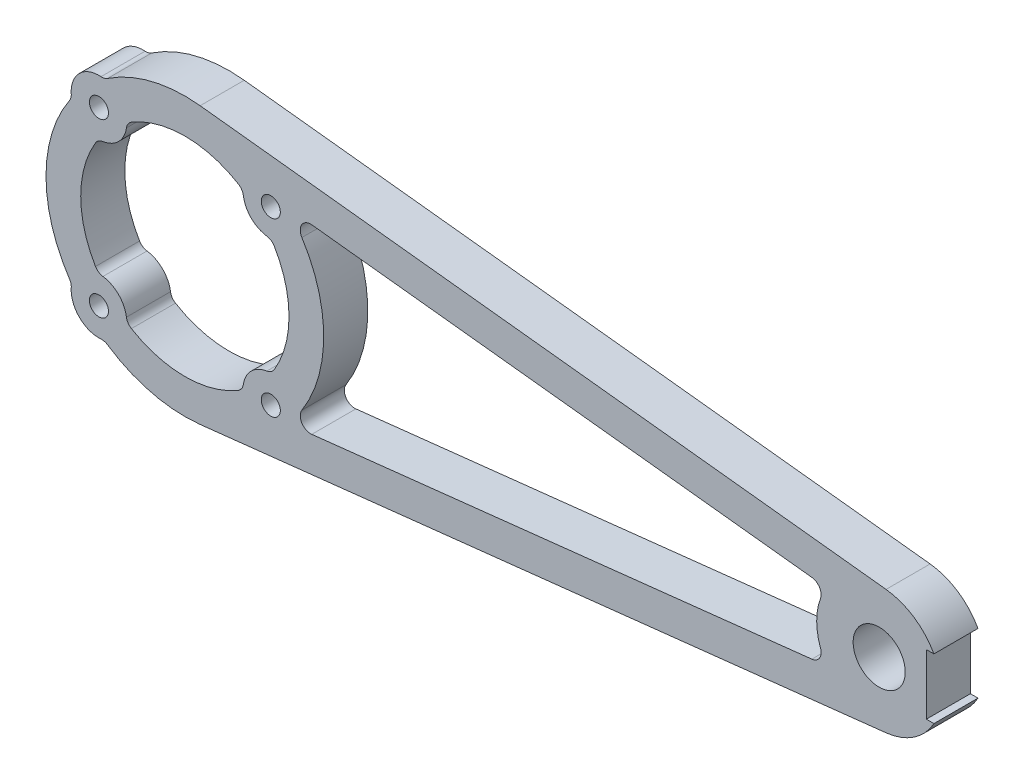
from build123d import *

# Parameters (mm, degrees)
SKETCH1_R           = 3.75
SKETCH1_R_2         = 1.375
BOSS_EXTRUDE1_DEPTH = 6.35


with BuildPart() as part:
    # Sketch1 → Boss-Extrude1 (new body)
    with BuildSketch(Plane(origin=(0, 0, 0), x_dir=(-1, 0, 0), z_dir=(0, 0, -1))):
        with BuildLine():
            Line((-106.79268786, -4.343029528), (-107.882772007, -4.343029528))
            ThreePointArc((-107.882772007, -4.343029528), (-104.997693278, -7.484855503), (-100.99, -8.945384285))
            Line((-100.99, -8.945384285), (-2.2, -19.878631744))
            ThreePointArc((-2.2, -19.878631744), (4.756528256, -19.426153478), (11.135161851, -16.613493629))
            ThreePointArc((11.135161851, -16.613493629), (11.586893238, -16.409333237), (12.080499812, -16.363559202))
            ThreePointArc((12.080499812, -16.363559202), (15.202795796, -15.202795795), (16.363559202, -12.080499812))
            ThreePointArc((16.363559202, -12.080499812), (16.409333237, -11.586893238), (16.613493629, -11.135161851))
            ThreePointArc((16.613493629, -11.135161851), (20, 0), (16.613493629, 11.135161851))
            ThreePointArc((16.613493629, 11.135161851), (16.409333237, 11.586893238), (16.363559202, 12.080499812))
            ThreePointArc((16.363559202, 12.080499812), (15.202795795, 15.202795795), (12.080499812, 16.363559202))
            ThreePointArc((12.080499812, 16.363559202), (11.586893238, 16.409333237), (11.135161851, 16.613493629))
            ThreePointArc((11.135161851, 16.613493629), (4.756528256, 19.426153478), (-2.2, 19.878631744))
            Line((-2.2, 19.878631744), (-100.99, 8.945384285))
            ThreePointArc((-100.99, 8.945384285), (-104.997693278, 7.484855504), (-107.882772007, 4.343029529))
            Line((-107.882772007, 4.343029529), (-106.79268786, 4.343029529))
            Line((-106.79268786, 4.343029529), (-106.79268786, -4.343029528))
        make_face()
        with Locations((-100, 0)):
            Circle(SKETCH1_R, mode=Mode.SUBTRACT)
        with Locations((12.374368671, -12.374368671)):
            Circle(SKETCH1_R_2, mode=Mode.SUBTRACT)
        with Locations((12.374368671, 12.374368671)):
            Circle(SKETCH1_R_2, mode=Mode.SUBTRACT)
        with Locations((-12.374368671, 12.374368671)):
            Circle(SKETCH1_R_2, mode=Mode.SUBTRACT)
        with Locations((-12.374368671, -12.374368671)):
            Circle(SKETCH1_R_2, mode=Mode.SUBTRACT)
        with BuildLine():
            Line((-18.281656562, -13.06832175), (-90.303846884, -5.097510642))
            ThreePointArc((-90.303846884, -5.097510642), (-91.413718881, -4.396993797), (-91.547583043, -3.091382795))
            ThreePointArc((-91.547583043, -3.091382795), (-91, 0), (-91.547583043, 3.091382796))
            ThreePointArc((-91.547583043, 3.091382796), (-91.413718881, 4.396993797), (-90.303846884, 5.097510642))
            Line((-90.303846884, 5.097510642), (-18.281656562, 13.068321749))
            ThreePointArc((-18.281656562, 13.068321749), (-16.842747955, 12.369356727), (-16.852703779, 10.769697087))
            ThreePointArc((-16.852703779, 10.769697087), (-20, 0), (-16.852703779, -10.769697087))
            ThreePointArc((-16.852703779, -10.769697087), (-16.842747955, -12.369356727), (-18.281656562, -13.06832175))
        make_face(mode=Mode.SUBTRACT)
        with BuildLine():
            ThreePointArc((-11.80010118, -8.415806198), (-12.416598495, -8.179555802), (-12.871945412, -7.701494746))
            ThreePointArc((-12.871945412, -7.701494746), (-15, 0), (-12.871945412, 7.701494746))
            ThreePointArc((-12.871945412, 7.701494746), (-12.416598495, 8.179555802), (-11.80010118, 8.415806198))
            ThreePointArc((-11.80010118, 8.415806198), (-9.545941546, 9.545941546), (-8.415806198, 11.80010118))
            ThreePointArc((-8.415806198, 11.80010118), (-8.179555802, 12.416598495), (-7.701494746, 12.871945412))
            ThreePointArc((-7.701494746, 12.871945412), (0, 15), (7.701494746, 12.871945412))
            ThreePointArc((7.701494746, 12.871945412), (8.179555802, 12.416598495), (8.415806198, 11.80010118))
            ThreePointArc((8.415806198, 11.80010118), (9.545941546, 9.545941546), (11.80010118, 8.415806198))
            ThreePointArc((11.80010118, 8.415806198), (12.416598495, 8.179555802), (12.871945412, 7.701494746))
            ThreePointArc((12.871945412, 7.701494746), (15, 0), (12.871945412, -7.701494746))
            ThreePointArc((12.871945412, -7.701494746), (12.416598495, -8.179555803), (11.80010118, -8.415806198))
            ThreePointArc((11.80010118, -8.415806198), (9.545941546, -9.545941546), (8.415806198, -11.80010118))
            ThreePointArc((8.415806198, -11.80010118), (8.179555803, -12.416598495), (7.701494746, -12.871945412))
            ThreePointArc((7.701494746, -12.871945412), (0, -15), (-7.701494746, -12.871945412))
            ThreePointArc((-7.701494746, -12.871945412), (-8.179555802, -12.416598495), (-8.415806198, -11.80010118))
            ThreePointArc((-8.415806198, -11.80010118), (-9.545941546, -9.545941546), (-11.80010118, -8.415806198))
        make_face(mode=Mode.SUBTRACT)
    extrude(amount=-BOSS_EXTRUDE1_DEPTH)


solid = part.part
